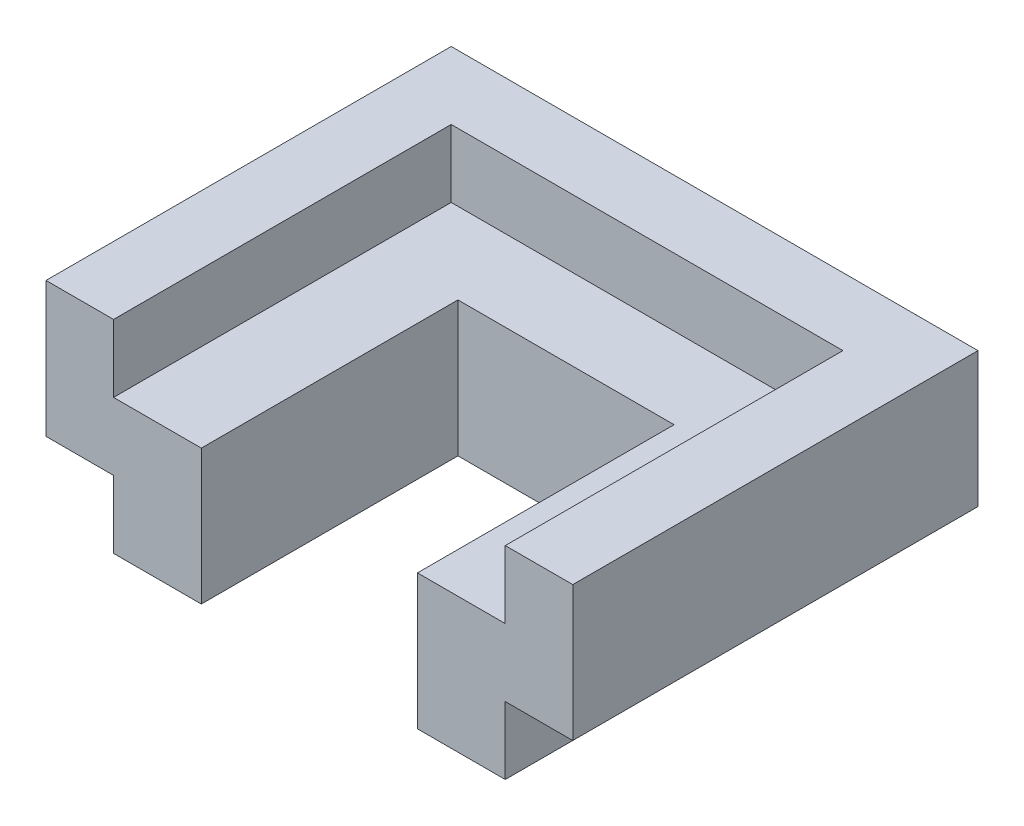
from build123d import *

# Parameters (mm, degrees)
EXTRUDE_1_DEPTH      = 10
EXTRUDE_2_DEPTH      = 5
EXTRUDE_2_DEPTH_BACK = 5
SKETCH_3_W           = 29
SKETCH_3_H           = 50
CUT_EXTRUDE_2_DEPTH  = 5


with BuildPart() as part:
    # 스케치1 → 보스-돌출1 (new body)
    with BuildSketch(Plane(origin=(0, 0, 0), x_dir=(1, 0, 0), z_dir=(0, 1, 0))):
        Polygon((-14.5, 0), (-8, 0), (-8, 19), (8, 19), (8, 0), (14.5, 0), (14.5, 25), (-14.5, 25), align=None)
    extrude(amount=EXTRUDE_1_DEPTH)

    # 스케치2 → 보스-돌출2 (add, two sides)
    with BuildSketch(Plane(origin=(0, 10, 0), x_dir=(1, 0, 0), z_dir=(0, 1, 0))) as extrude_2_sk:
        Polygon((-8, 0), (-19.5, 0), (-19.5, 30), (19.5, 30), (19.5, 0), (8, 0), (8, 19), (-8, 19), align=None)
    extrude(amount=EXTRUDE_2_DEPTH)
    extrude(extrude_2_sk.sketch, amount=-EXTRUDE_2_DEPTH_BACK)

    # 스케치3 → 컷-돌출2 (cut)
    with BuildSketch(Plane(origin=(0, 15, 0), x_dir=(1, 0, 0), z_dir=(0, 1, 0))):
        Rectangle(SKETCH_3_W, SKETCH_3_H)
    extrude(amount=-CUT_EXTRUDE_2_DEPTH, mode=Mode.SUBTRACT)


solid = part.part
